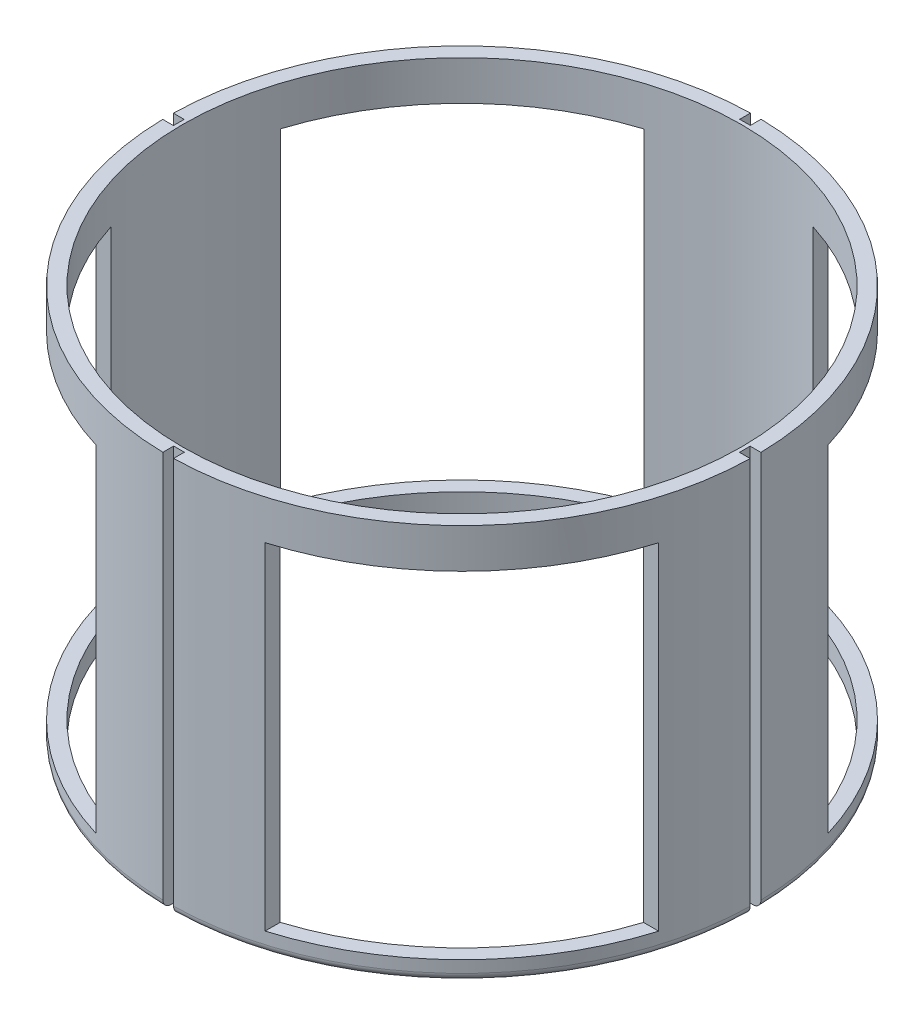
from build123d import *

# Parameters (mm, degrees)
SKETCH1_R           = 94.2975
SKETCH1_R_2         = 89.662
BOSS_EXTRUDE1_DEPTH = 127
SKETCH5_W           = 3.429
SKETCH5_H           = 5.08
SKETCH5_W_2         = 5.08
SKETCH5_H_2         = 3.429
CUT_EXTRUDE1_DEPTH  = 127
CUT_EXTRUDE2_START  = -12.7
CUT_EXTRUDE2_DEPTH  = 107.95
CIRPATTERN1_COUNT   = 4
FILLET1_R           = 2.54


with BuildPart() as part:
    # Sketch1 → Boss-Extrude1 (new body)
    with BuildSketch(Plane(origin=(0, 0, 0), x_dir=(1, 0, 0), z_dir=(0, 1, 0))):
        Circle(SKETCH1_R)
        Circle(SKETCH1_R_2, mode=Mode.SUBTRACT)
    extrude(amount=-BOSS_EXTRUDE1_DEPTH)

    # Sketch5 → Cut-Extrude1 (cut)
    with BuildSketch(Plane(origin=(0, 0, 0), x_dir=(1, 0, 0), z_dir=(0, 1, 0))):
        with Locations((0, 93.360875)):
            Rectangle(SKETCH5_W, SKETCH5_H)
        with Locations((0, -93.360875)):
            Rectangle(SKETCH5_W, SKETCH5_H)
        with Locations((-93.360875, -0.0635)):
            Rectangle(SKETCH5_W_2, SKETCH5_H_2)
        with Locations((93.360875, -0.0635)):
            Rectangle(SKETCH5_W_2, SKETCH5_H_2)
    extrude(amount=-CUT_EXTRUDE1_DEPTH, mode=Mode.SUBTRACT)

    # Sketch7 → Cut-Extrude2 (cut)
    with BuildSketch(Plane(origin=(0, 0, 0), x_dir=(1, 0, 0), z_dir=(0, 1, 0)).offset(CUT_EXTRUDE2_START)):
        with BuildLine():
            Line((85.443727447, -27.178), (90.296039903, -27.178))
            ThreePointArc((90.296039903, -27.178), (66.654954519, -66.701840637), (27.1145, -90.315128279))
            Line((27.1145, -90.315128279), (27.1145, -85.463899594))
            ThreePointArc((27.1145, -85.463899594), (63.377047615, -63.424160063), (85.443727447, -27.178))
        make_face()
    cut_extrude2 = extrude(amount=-CUT_EXTRUDE2_DEPTH, mode=Mode.SUBTRACT)

    # CirPattern1: Cut-Extrude2 ×4 about axis
    cirpattern1_axis = Axis((0, 0, 0), (0, 1, 0))
    for i in range(1, CIRPATTERN1_COUNT):
        add(cut_extrude2.rotate(cirpattern1_axis, i * 360 / CIRPATTERN1_COUNT), mode=Mode.SUBTRACT)

    # Fillet1
    fillet1_edges = [part.edges().sort_by_distance(p)[0] for p in [
        (66.700852134, -127, -66.655943702),
        (-66.700852134, -127, -66.655943702),
        (-66.655943427, -127, 66.700852409),
        (66.655943427, -127, 66.700852409),
    ]]
    fillet(fillet1_edges, radius=FILLET1_R)


solid = part.part
